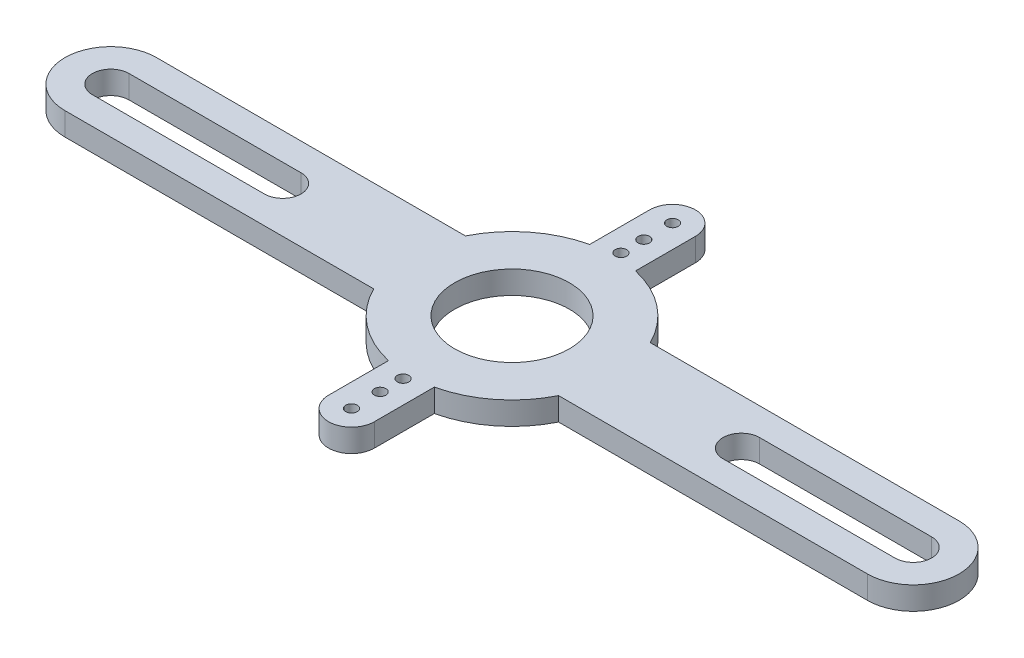
from build123d import *

# Parameters (mm, degrees)
SKETCH1_R               = 1.6
BOSS_EXTRUDE1_DEPTH     = 2
SKETCH2_R               = 0.5
BOSS_EXTRUDE2_DEPTH     = 2
SKETCH3_R               = 1.6
BOSS_EXTRUDE3_DEPTH     = 4
SKETCH4_R               = 5.618069601
SKETCH4_R_2             = 1.5
SKETCH4_R_3             = 9.019483561
CUT_EXTRUDE1_DEPTH      = 20
CUT_EXTRUDE2_DEPTH      = 10
CUT_EXTRUDE2_DEPTH_BACK = 10
SKETCH6_W               = 4
SKETCH6_H               = 1
SKETCH6_R               = 0.5
BOSS_EXTRUDE5_DEPTH     = 2
SKETCH7_R               = 9
SKETCH7_R_2             = 5
BOSS_EXTRUDE6_DEPTH     = 2
SKETCH8_R               = 5
CUT_EXTRUDE3_DEPTH      = 10


with BuildPart() as part:
    # Sketch1 → Boss-Extrude1 (new body)
    with BuildSketch(Plane(origin=(0, 0, 0), x_dir=(1, 0, 0), z_dir=(0, 1, 0))):
        with BuildLine():
            Line((0, 3), (70, 3))
            ThreePointArc((70, 3), (73, 0), (70, -3))
            Line((70, -3), (0, -3))
            ThreePointArc((0, -3), (-3, 0), (0, 3))
        make_face()
        Circle(SKETCH1_R, mode=Mode.SUBTRACT)
        with Locations((70, 0)):
            Circle(SKETCH1_R, mode=Mode.SUBTRACT)
        with Locations((35, 0)):
            Circle(SKETCH1_R, mode=Mode.SUBTRACT)
    extrude(amount=BOSS_EXTRUDE1_DEPTH)

    # Sketch2 → Boss-Extrude2 (add)
    with BuildSketch(Plane(origin=(0, 2, 0), x_dir=(1, 0, 0), z_dir=(0, 1, 0))):
        with BuildLine():
            Line((37, -3), (33, -3))
            Line((33, -3), (33, -14))
            ThreePointArc((33, -14), (35, -16), (37, -14))
            Line((37, -14), (37, -3))
        make_face()
        with Locations((35, -11.5)):
            Circle(SKETCH2_R, mode=Mode.SUBTRACT)
        with Locations((35, -14)):
            Circle(SKETCH2_R, mode=Mode.SUBTRACT)
        with Locations((35, -9.5)):
            Circle(SKETCH2_R, mode=Mode.SUBTRACT)
        with BuildLine():
            Line((33, 14), (33, 3))
            Line((33, 3), (37, 3))
            Line((37, 3), (37, 14))
            ThreePointArc((37, 14), (35, 16), (33, 14))
        make_face()
        with Locations((35, 9.5)):
            Circle(SKETCH2_R, mode=Mode.SUBTRACT)
        with Locations((35, 14)):
            Circle(SKETCH2_R, mode=Mode.SUBTRACT)
        with Locations((35, 11.5)):
            Circle(SKETCH2_R, mode=Mode.SUBTRACT)
    extrude(amount=-BOSS_EXTRUDE2_DEPTH)

    # Sketch3 → Boss-Extrude3 (add)
    with BuildSketch(Plane(origin=(0, 0, 0), x_dir=(-1, 0, 0), z_dir=(0, -1, 0))):
        with Locations((-70, 0)):
            Circle(SKETCH3_R)
        Circle(SKETCH3_R)
    extrude(amount=-BOSS_EXTRUDE3_DEPTH)

    # Sketch4 → Cut-Extrude1 (cut)
    with BuildSketch(Plane(origin=(0, 2, 0), x_dir=(1, 0, 0), z_dir=(0, 1, 0))):
        with Locations((70, 0)):
            Circle(SKETCH4_R)
        with Locations((70, 0)):
            Circle(SKETCH4_R_2, mode=Mode.SUBTRACT)
        Circle(SKETCH4_R_3)
        Circle(SKETCH4_R_2, mode=Mode.SUBTRACT)
    extrude(amount=CUT_EXTRUDE1_DEPTH, mode=Mode.SUBTRACT)

    # Sketch5 → Cut-Extrude2 (cut, two sides)
    with BuildSketch(Plane(origin=(0, 2, 0), x_dir=(1, 0, 0), z_dir=(0, 1, 0))) as cut_extrude2_sk:
        with BuildLine():
            Line((55, 1.6), (70, 1.6))
            ThreePointArc((70, 1.6), (71.6, 0), (70, -1.6))
            Line((70, -1.6), (55, -1.6))
            ThreePointArc((55, -1.6), (53.4, 0), (55, 1.6))
        make_face()
        with BuildLine():
            Line((0, -1.6), (15, -1.6))
            ThreePointArc((15, -1.6), (16.6, 0), (15, 1.6))
            Line((15, 1.6), (0, 1.6))
            ThreePointArc((0, 1.6), (-1.6, 0), (0, -1.6))
        make_face()
    extrude(amount=CUT_EXTRUDE2_DEPTH, mode=Mode.SUBTRACT)
    extrude(cut_extrude2_sk.sketch, amount=-CUT_EXTRUDE2_DEPTH_BACK, mode=Mode.SUBTRACT)

    # Sketch6 → Boss-Extrude5 (add)
    with BuildSketch(Plane(origin=(0, 2, 0), x_dir=(1, 0, 0), z_dir=(0, 1, 0))):
        with Locations((35, 3.5)):
            Rectangle(SKETCH6_W, SKETCH6_H)
        with BuildLine():
            Line((33, 4), (0, 4))
            ThreePointArc((0, 4), (-4, 0), (0, -4))
            Line((0, -4), (33, -4))
            Line((33, -4), (33, -3))
            Line((33, -3), (0, -3))
            ThreePointArc((0, -3), (-3, 0), (0, 3))
            Line((0, 3), (33, 3))
            Line((33, 3), (33, 4))
        make_face()
        with BuildLine():
            Line((70, 4), (37, 4))
            Line((37, 4), (37, 3))
            Line((37, 3), (70, 3))
            ThreePointArc((70, 3), (73, 0), (70, -3))
            Line((70, -3), (37, -3))
            Line((37, -3), (37, -4))
            Line((37, -4), (70, -4))
            ThreePointArc((70, -4), (74, 0), (70, 4))
        make_face()
        with Locations((35, -3.5)):
            Rectangle(SKETCH6_W, SKETCH6_H)
        with BuildLine():
            Line((33, 14), (33, 4))
            Line((33, 4), (37, 4))
            Line((37, 4), (37, 14))
            ThreePointArc((37, 14), (35, 16), (33, 14))
        make_face()
        with Locations((35, 9.5)):
            Circle(SKETCH6_R, mode=Mode.SUBTRACT)
        with Locations((35, 11.5)):
            Circle(SKETCH6_R, mode=Mode.SUBTRACT)
        with Locations((35, 14)):
            Circle(SKETCH6_R, mode=Mode.SUBTRACT)
    extrude(amount=-BOSS_EXTRUDE5_DEPTH)

    # Sketch7 → Boss-Extrude6 (add)
    with BuildSketch(Plane(origin=(0, 2, 0), x_dir=(1, 0, 0), z_dir=(0, 1, 0))):
        with Locations((35, 0)):
            Circle(SKETCH7_R)
        with Locations((35, 0)):
            Circle(SKETCH7_R_2, mode=Mode.SUBTRACT)
    extrude(amount=-BOSS_EXTRUDE6_DEPTH)

    # Sketch8 → Cut-Extrude3 (cut)
    with BuildSketch(Plane(origin=(0, 2, 0), x_dir=(1, 0, 0), z_dir=(0, 1, 0))):
        with Locations((35, 0)):
            Circle(SKETCH8_R)
    extrude(amount=-CUT_EXTRUDE3_DEPTH, mode=Mode.SUBTRACT)


solid = part.part
